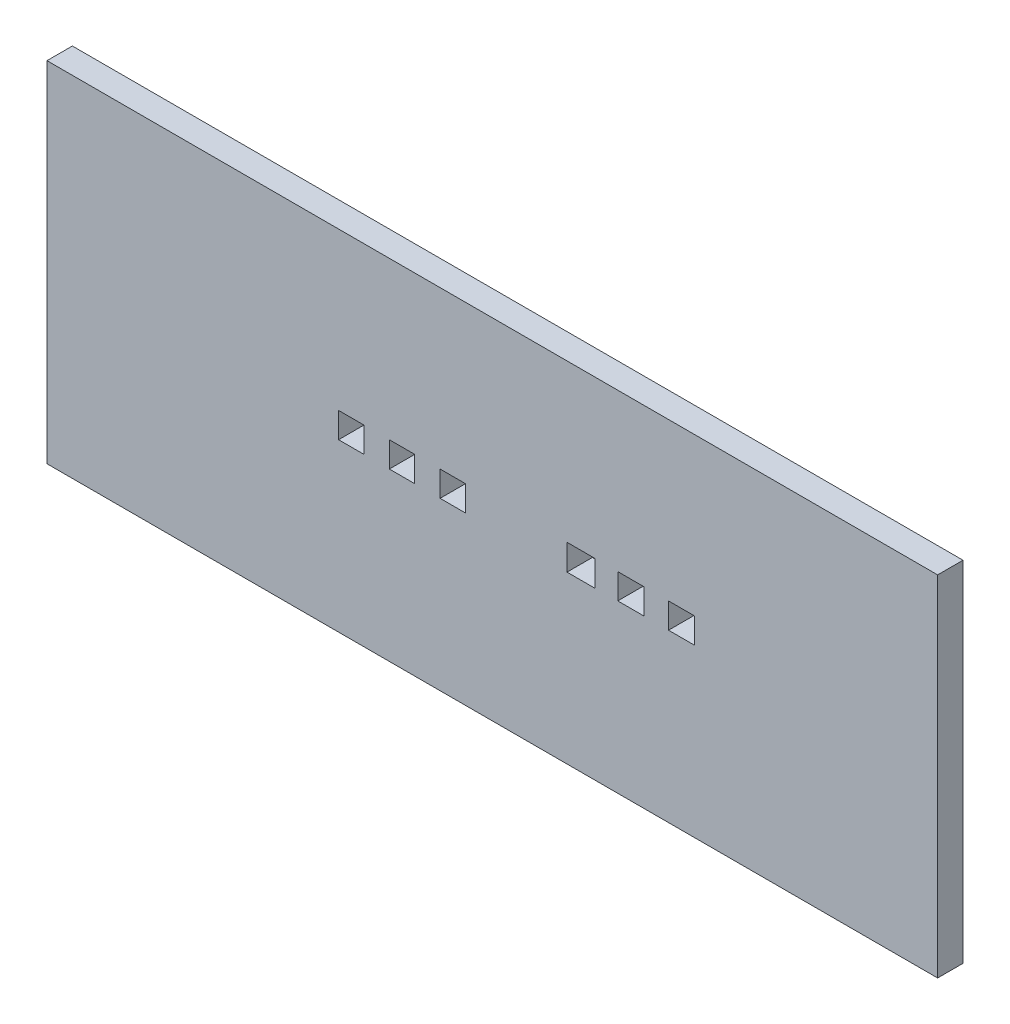
from build123d import *

# Parameters (mm, degrees)
SKETCH2_W           = 222.838700845
SKETCH2_H           = 87.350424545
SKETCH2_W_2         = 6.35
SKETCH2_H_2         = 6.35
SKETCH2_W_3         = 6.952051191
SKETCH2_H_3         = 6.464241918
SKETCH2_W_4         = 6.555527472
BOSS_EXTRUDE1_DEPTH = 6.35


with BuildPart() as part:
    # Sketch2 → Boss-Extrude1 (new body)
    with BuildSketch(Plane.XY):
        with Locations((-5.990892188, -4.367938815)):
            Rectangle(SKETCH2_W, SKETCH2_H)
        with Locations((-41.275000024, -3.175)):
            Rectangle(SKETCH2_W_2, SKETCH2_H_2, mode=Mode.SUBTRACT)
        with Locations((-28.575000024, -3.175)):
            Rectangle(SKETCH2_W_2, SKETCH2_H_2, mode=Mode.SUBTRACT)
        with Locations((-15.875000024, -3.175)):
            Rectangle(SKETCH2_W_2, SKETCH2_H_2, mode=Mode.SUBTRACT)
        with Locations((16.176025571, -3.232120959)):
            Rectangle(SKETCH2_W_3, SKETCH2_H_3, mode=Mode.SUBTRACT)
        with Locations((28.677763712, -3.175)):
            Rectangle(SKETCH2_W_4, SKETCH2_H_2, mode=Mode.SUBTRACT)
        with Locations((41.377763712, -3.175)):
            Rectangle(SKETCH2_W_4, SKETCH2_H_2, mode=Mode.SUBTRACT)
    extrude(amount=BOSS_EXTRUDE1_DEPTH)


solid = part.part
